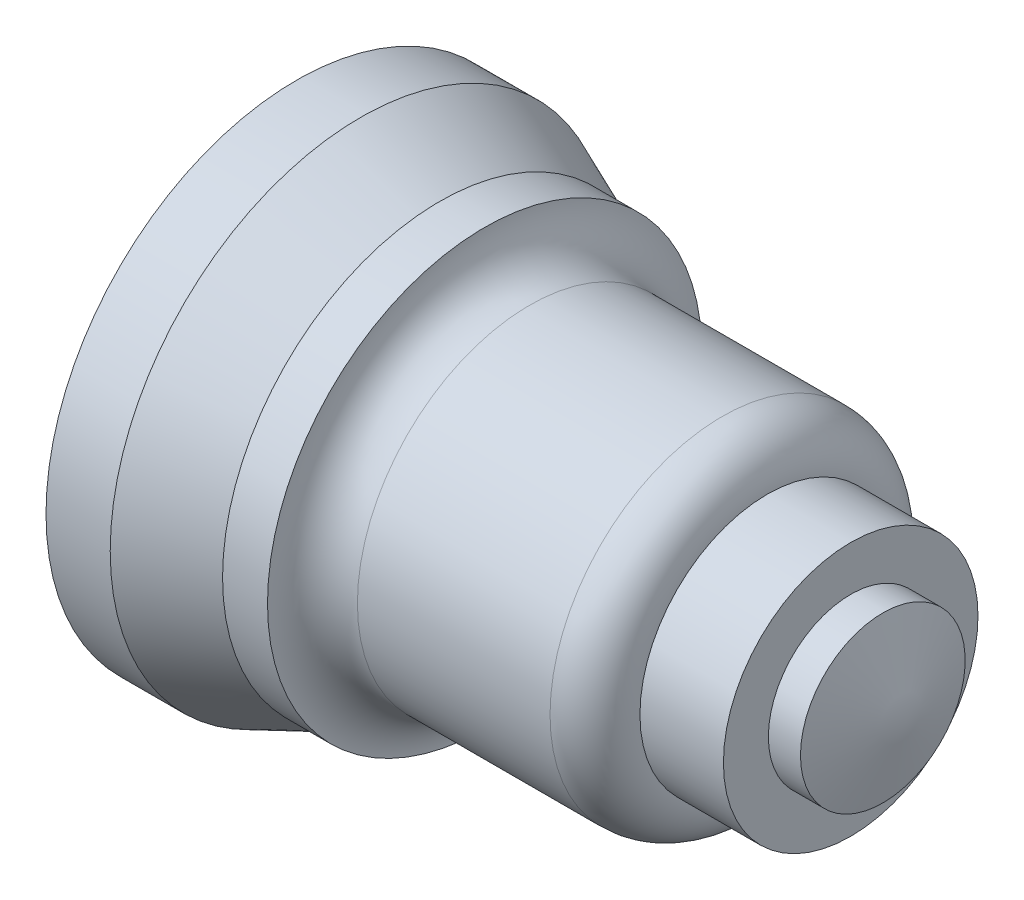
from build123d import *


with BuildPart() as part:
    # Sketch1 → Revolve5 (revolve)
    with BuildSketch(Plane.XY):
        with BuildLine():
            Line((0, 0), (120.65, 0))
            Line((120.65, 0), (115.974515988, 16.285996254))
            Line((115.974515988, 16.285996254), (109.624515988, 16.285996254))
            Line((109.624515988, 16.285996254), (109.624515988, 25.175996254))
            Line((109.624515988, 25.175996254), (93.114515988, 25.175996254))
            ThreePointArc((93.114515988, 25.175996254), (90.510695272, 31.462175539), (84.224515988, 34.065996254))
            Line((84.224515988, 34.065996254), (46.124515988, 34.065996254))
            ThreePointArc((46.124515988, 34.065996254), (39.838336703, 36.66981697), (37.234515988, 42.955996254))
            Line((37.234515988, 42.955996254), (28.344515988, 42.955996254))
            Line((28.344515988, 42.955996254), (12.7, 49.53))
            Line((12.7, 49.53), (0, 49.53))
            Line((0, 49.53), (0, 0))
        make_face()
    revolve(axis=Axis((0, 0, 0), (1, 0, 0)))


solid = part.part
